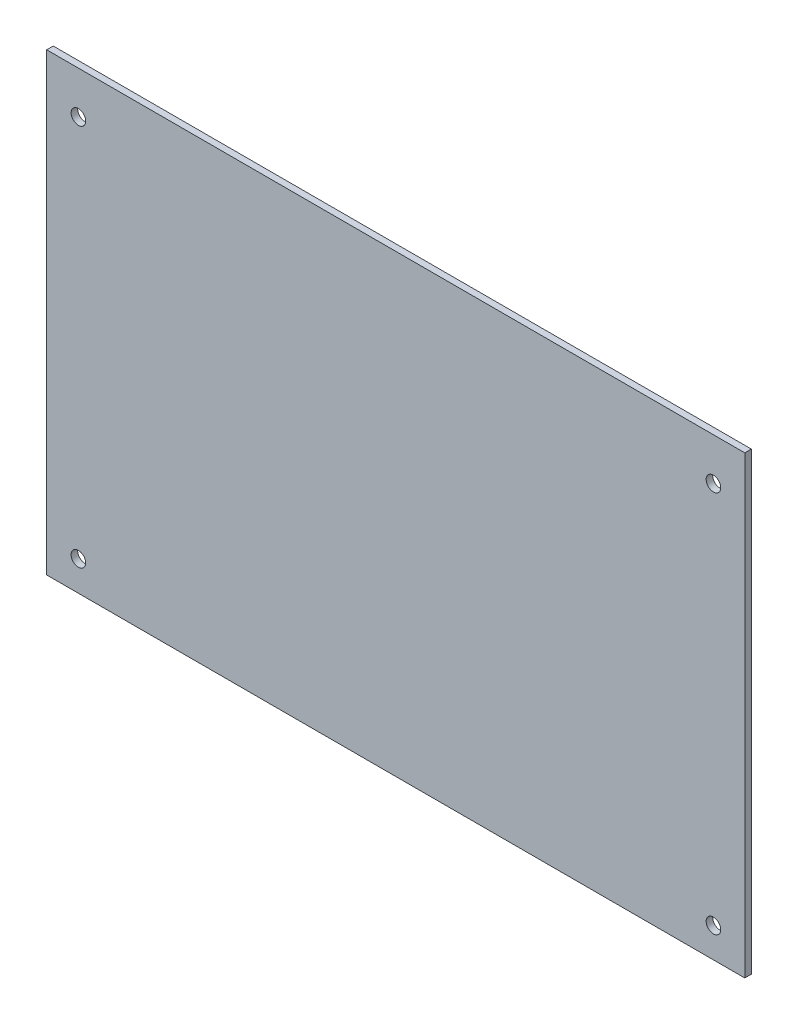
from build123d import *

# Parameters (mm, degrees)
SKETCH1_W            = 167.64
SKETCH1_H            = 109.22
PCB_DEPTH            = 1.5748
SKETCH2_R            = 1.75
MOUNT_HOLE_CUT_DEPTH = 1.5748
LPATTERN1_COUNT      = 2
LPATTERN1_PITCH      = 152.5
LPATTERN1_COUNT_DIR2 = 2
LPATTERN1_PITCH_DIR2 = 91.9
SKETCH3_W            = 7.463209877
SKETCH3_H            = 6.129068463
EXTRUDE1_DEPTH       = 3.75


with BuildPart() as part:
    # Sketch1 → PCB (new body)
    with BuildSketch(Plane.XY):
        with Locations((46.345343175, 16.988671329)):
            Rectangle(SKETCH1_W, SKETCH1_H)
    extrude(amount=PCB_DEPTH)

    # Sketch2 → mount hole cut (cut)
    with BuildSketch(Plane.XY.offset(1.5748)):
        with Locations((-29.854656825, 61.438671329)):
            Circle(SKETCH2_R)
    mount_hole_cut = extrude(amount=-MOUNT_HOLE_CUT_DEPTH, mode=Mode.SUBTRACT)

    # LPattern1: mount hole cut 2 × 2
    with Locations(*[(i * LPATTERN1_PITCH, -j * LPATTERN1_PITCH_DIR2, 0) for i in range(LPATTERN1_COUNT) for j in range(LPATTERN1_COUNT_DIR2) if (i, j) != (0, 0)]):
        add(mount_hole_cut, mode=Mode.SUBTRACT)

    # Sketch3 → Extrude1 (add)
    with BuildSketch(Plane(origin=(0, 0, 0), x_dir=(-1, 0, 0), z_dir=(0, 0, -1))):
        with Locations((7.354656825, -1.991328672)):
            Rectangle(SKETCH3_W, SKETCH3_H)
    extrude(amount=EXTRUDE1_DEPTH)


solid = part.part
